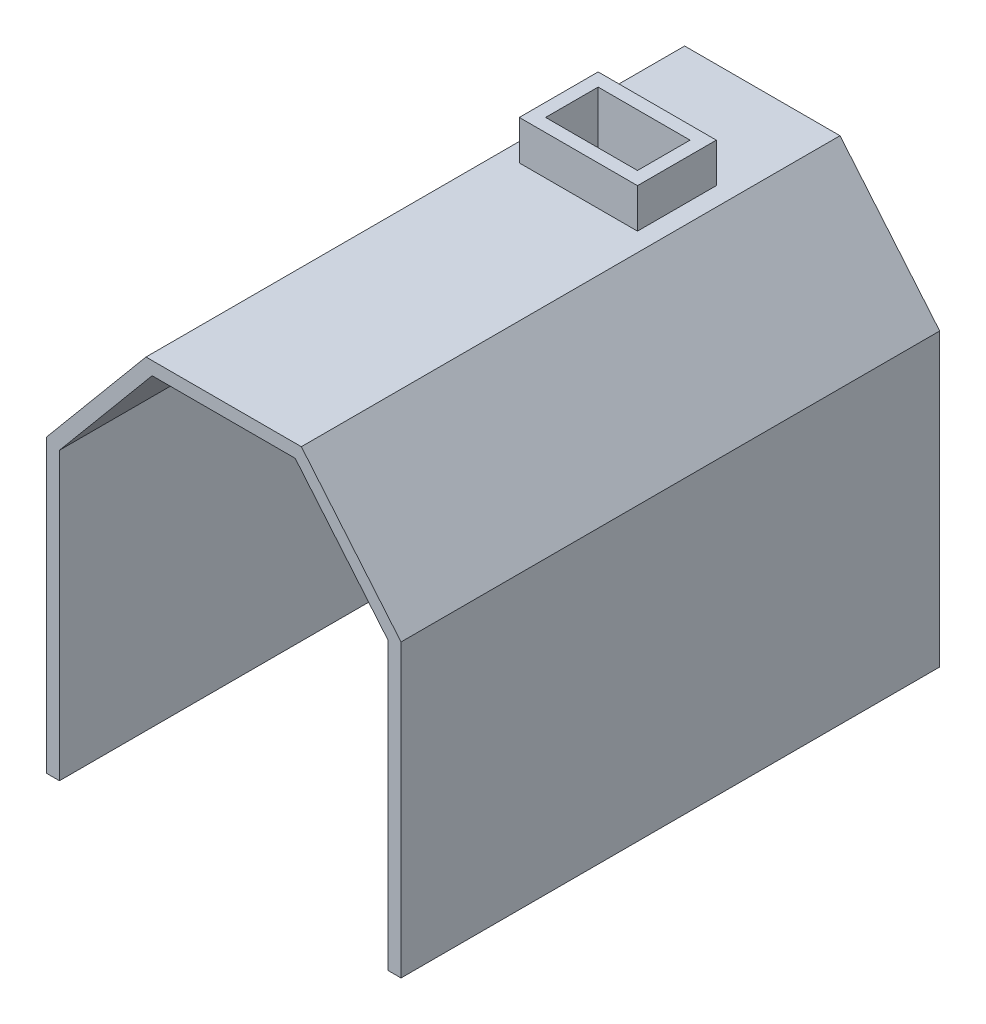
from build123d import *

# Parameters (mm, degrees)
BOSS_EXTRUDE1_DEPTH = 205
SKETCH2_W           = 69.949988916
SKETCH2_H           = 40
CUT_EXTRUDE1_DEPTH  = 204.35
BOSS_EXTRUDE2_START = 203.35
SKETCH3_W           = 89.949988916
SKETCH3_H           = 60
SKETCH3_W_2         = 69.949988916
SKETCH3_H_2         = 40
BOSS_EXTRUDE2_DEPTH = 30


with BuildPart() as part:
    # Sketch1 → Boss-Extrude1 (new body, symmetric)
    with BuildSketch(Plane.XY):
        Polygon((-125, 108.94), (-54.45, 193.35), (54.45, 193.35), (125, 108.94), (125, -108.94), (135, -108.94), (135, 112.568729132), (59.1248826, 203.35), (-59.1248826, 203.35), (-135, 112.568729132), (-135, -108.94), (-125, -108.94), align=None)
    extrude(amount=BOSS_EXTRUDE1_DEPTH, both=True)

    # Sketch2 → Cut-Extrude1 (cut, through all)
    with BuildSketch(Plane(origin=(0, 0, 0), x_dir=(1, 0, 0), z_dir=(0, 1, 0))):
        with Locations((0, 95)):
            Rectangle(SKETCH2_W, SKETCH2_H)
    extrude(amount=CUT_EXTRUDE1_DEPTH, mode=Mode.SUBTRACT)

    # Sketch3 → Boss-Extrude2 (add)
    with BuildSketch(Plane(origin=(0, 0, 0), x_dir=(1, 0, 0), z_dir=(0, 1, 0)).offset(BOSS_EXTRUDE2_START)):
        with Locations((0, 95)):
            Rectangle(SKETCH3_W, SKETCH3_H)
        with Locations((0, 95)):
            Rectangle(SKETCH3_W_2, SKETCH3_H_2, mode=Mode.SUBTRACT)
    extrude(amount=BOSS_EXTRUDE2_DEPTH)


solid = part.part
